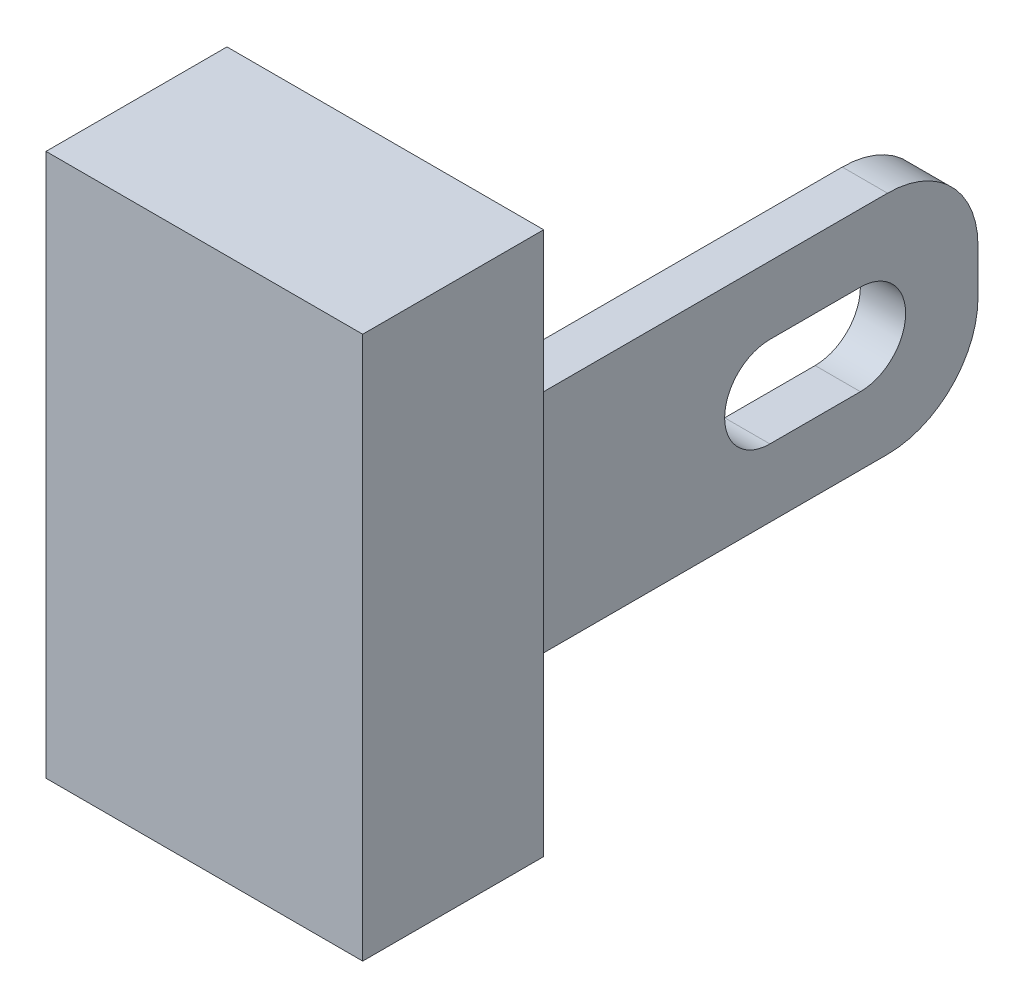
from build123d import *

# Parameters (mm, degrees)
SKETCH1_W           = 3.5
SKETCH1_H           = 6
BOSS_EXTRUDE1_DEPTH = 2
SKETCH2_W           = 0.5
SKETCH2_H           = 2.5
BOSS_EXTRUDE2_DEPTH = 5
FILLET1_R           = 1
CUT_EXTRUDE1_DEPTH  = 4.3


with BuildPart() as part:
    # Sketch1 → Boss-Extrude1 (new body)
    with BuildSketch(Plane.XY):
        Rectangle(SKETCH1_W, SKETCH1_H)
    extrude(amount=BOSS_EXTRUDE1_DEPTH)

    # Sketch2 → Boss-Extrude2 (add)
    with BuildSketch(Plane(origin=(0, 0, 0), x_dir=(-1, 0, 0), z_dir=(0, 0, -1))):
        with Locations((-1.3, 0)):
            Rectangle(SKETCH2_W, SKETCH2_H)
    extrude(amount=BOSS_EXTRUDE2_DEPTH)

    # Fillet1
    fillet1_edges = [part.edges().sort_by_distance(p)[0] for p in [
        (1.3, 1.25, -5),
        (1.3, -1.25, -5),
    ]]
    fillet(fillet1_edges, radius=FILLET1_R)

    # Sketch3 → Cut-Extrude1 (cut, through all)
    with BuildSketch(Plane(origin=(1.55, 0, 0), x_dir=(0, 0, -1), z_dir=(1, 0, 0))):
        with BuildLine():
            Line((2.7, 0.5), (3.7, 0.5))
            ThreePointArc((3.7, 0.5), (4.2, 0), (3.7, -0.5))
            Line((3.7, -0.5), (2.7, -0.5))
            ThreePointArc((2.7, -0.5), (2.2, 0), (2.7, 0.5))
        make_face()
    extrude(amount=-CUT_EXTRUDE1_DEPTH, mode=Mode.SUBTRACT)


solid = part.part
